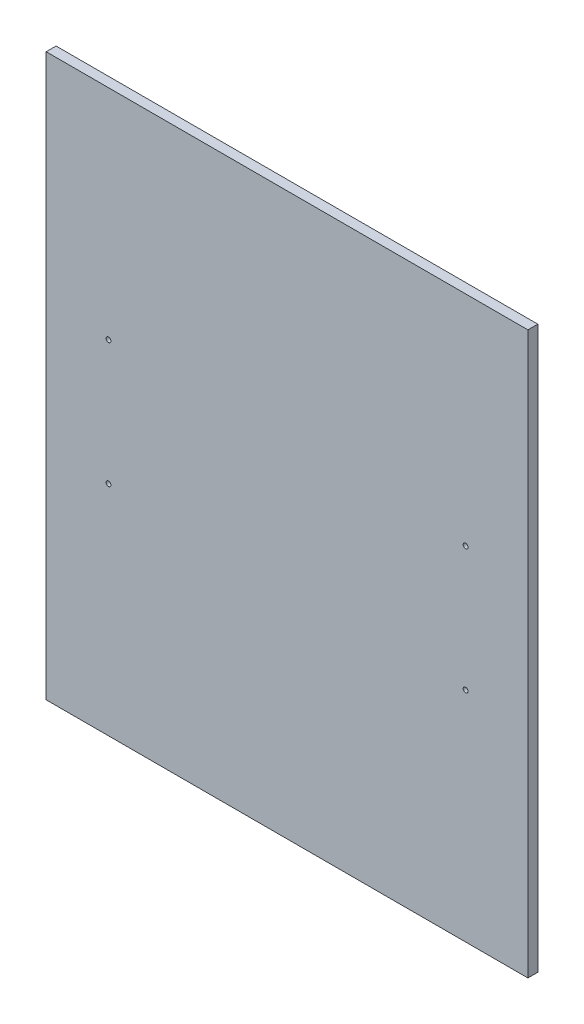
from build123d import *

# Parameters (mm, degrees)
SKETCH1_W           = 309
SKETCH1_H           = 360
SKETCH1_R           = 1.55
BOSS_EXTRUDE1_DEPTH = 6.35


with BuildPart() as part:
    # Sketch1 → Boss-Extrude1 (new body)
    with BuildSketch(Plane.XY):
        with Locations((154.5, 180)):
            Rectangle(SKETCH1_W, SKETCH1_H)
        with Locations((40, 220)):
            Circle(SKETCH1_R, mode=Mode.SUBTRACT)
        with Locations((40, 140)):
            Circle(SKETCH1_R, mode=Mode.SUBTRACT)
        with Locations((269, 140)):
            Circle(SKETCH1_R, mode=Mode.SUBTRACT)
        with Locations((269, 220)):
            Circle(SKETCH1_R, mode=Mode.SUBTRACT)
    extrude(amount=BOSS_EXTRUDE1_DEPTH)


solid = part.part
